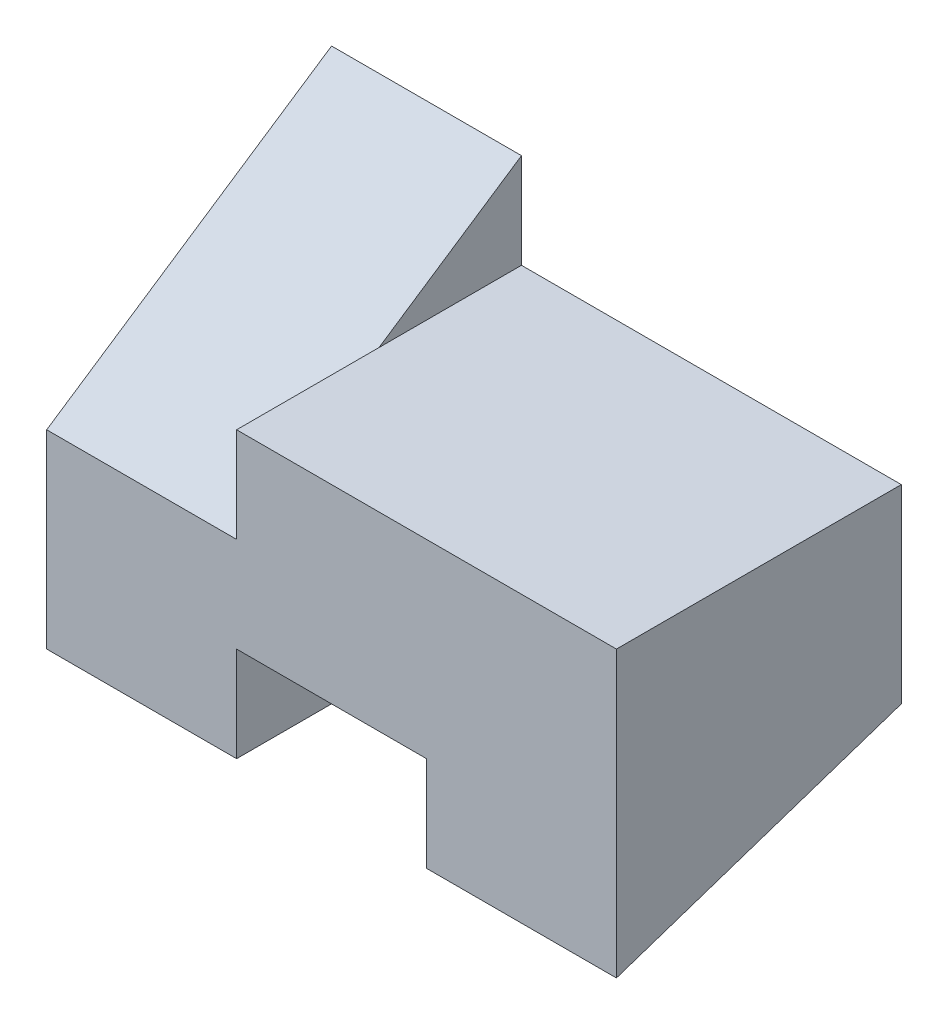
from build123d import *

# Parameters (mm, degrees)
BOSS_EXTRUDE1_DEPTH  = 15
BOSS_EXTRUDE8_DEPTH  = 10
SKETCH5_W            = 15
SKETCH5_H            = 15
BOSS_EXTRUDE10_DEPTH = 10
CUT_EXTRUDE4_DEPTH   = 10
BOSS_EXTRUDE11_DEPTH = 10


with BuildPart() as part:
    # Sketch1 → Boss-Extrude1 (new body)
    with BuildSketch(Plane.XY):
        Polygon((-20, -5), (-20, 5), (-10, 5), (-10, 10), (0, 10), (0, 0), (-10, 0), (-10, -5), align=None)
    extrude(amount=BOSS_EXTRUDE1_DEPTH)

    # Sketch2 → Boss-Extrude8 (add)
    with BuildSketch(Plane(origin=(-10, 0, 0), x_dir=(0, 0, -1), z_dir=(1, 0, 0))):
        Polygon((0, 0), (0, -5), (-15, 0), align=None)
    extrude(amount=BOSS_EXTRUDE8_DEPTH)

    # Sketch5 → Boss-Extrude10 (add)
    with BuildSketch(Plane(origin=(0, 0, 0), x_dir=(0, 0, -1), z_dir=(1, 0, 0))):
        with Locations((-7.5, 2.5)):
            Rectangle(SKETCH5_W, SKETCH5_H)
    extrude(amount=BOSS_EXTRUDE10_DEPTH)

    # Sketch6 → Cut-Extrude4 (cut)
    with BuildSketch(Plane(origin=(10, 0, 0), x_dir=(0, 0, -1), z_dir=(1, 0, 0))):
        Polygon((-15, -5), (0, 0), (0, -5), align=None)
    extrude(amount=-CUT_EXTRUDE4_DEPTH, mode=Mode.SUBTRACT)

    # Sketch7 → Boss-Extrude11 (add)
    with BuildSketch(Plane.ZY.offset(10)):
        Polygon((0, 5), (0, 15), (15, 5), align=None)
    extrude(amount=BOSS_EXTRUDE11_DEPTH)


solid = part.part
